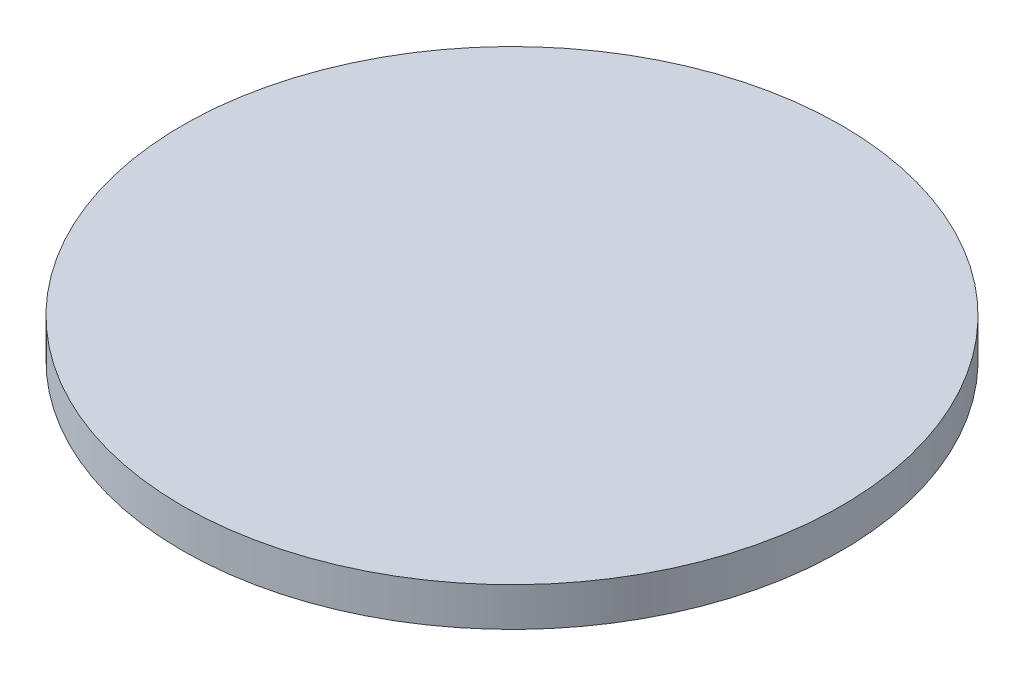
from build123d import *

# Parameters (mm, degrees)
SKETCH1_R           = 2.125
BOSS_EXTRUDE1_DEPTH = 0.25


with BuildPart() as part:
    # Sketch1 → Boss-Extrude1 (new body)
    with BuildSketch(Plane(origin=(0, 0, 0), x_dir=(1, 0, 0), z_dir=(0, 1, 0))):
        Circle(SKETCH1_R)
    extrude(amount=BOSS_EXTRUDE1_DEPTH)


solid = part.part
